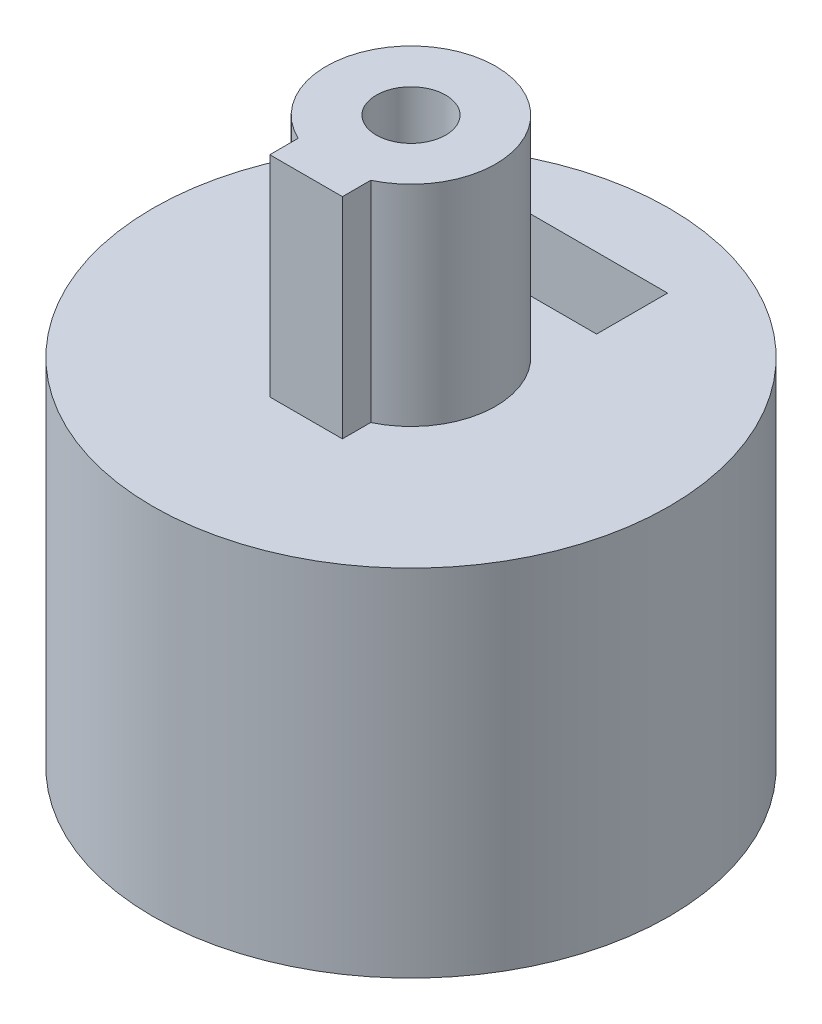
from build123d import *

# Parameters (mm, degrees)
SKETCH1_R           = 8
BOSS_EXTRUDE1_DEPTH = 10
SKETCH2_R           = 1.075
CUT_EXTRUDE1_DEPTH  = 9
SKETCH4_R           = 2.275
CUT_EXTRUDE4_DEPTH  = 11.0000001
SKETCH5_W           = 0.95
SKETCH5_H           = 7.069146706
BOSS_EXTRUDE2_DEPTH = 1.2
SKETCH7_R           = 8
BOSS_EXTRUDE3_DEPTH = 1
SKETCH8_R           = 2.625
SKETCH8_W           = 2.25
SKETCH8_H           = 1.25
BOSS_EXTRUDE4_DEPTH = 6.5
SKETCH9_R           = 1.075
CUT_EXTRUDE5_DEPTH  = 6
CUT_EXTRUDE2_START  = -3.5
CUT_EXTRUDE2_DEPTH  = 2.2


with BuildPart() as part:
    # Sketch1 → Boss-Extrude1 (new body)
    with BuildSketch(Plane(origin=(0, 0, 0), x_dir=(1, 0, 0), z_dir=(0, 1, 0))):
        Circle(SKETCH1_R)
    extrude(amount=BOSS_EXTRUDE1_DEPTH)

    # Sketch2 → Cut-Extrude1 (cut, through all)
    with BuildSketch(Plane.XY):
        with Locations((0, 7)):
            Circle(SKETCH2_R)
    extrude(amount=-CUT_EXTRUDE1_DEPTH, mode=Mode.SUBTRACT)

    # Sketch4 → Cut-Extrude4 (cut, through all)
    with BuildSketch(Plane(origin=(0, 0, 0), x_dir=(1, 0, 0), z_dir=(0, 1, 0))):
        Circle(SKETCH4_R)
    extrude(amount=CUT_EXTRUDE4_DEPTH, mode=Mode.SUBTRACT)

    # Sketch5 → Boss-Extrude2 (add)
    with BuildSketch(Plane(origin=(0, 10, 0), x_dir=(1, 0, 0), z_dir=(0, 1, 0))):
        Rectangle(SKETCH5_W, SKETCH5_H)
    extrude(amount=-BOSS_EXTRUDE2_DEPTH)

    # Sketch7 → Boss-Extrude3 (add)
    with BuildSketch(Plane(origin=(0, 10, 0), x_dir=(1, 0, 0), z_dir=(0, 1, 0))):
        Circle(SKETCH7_R)
    extrude(amount=BOSS_EXTRUDE3_DEPTH)

    # Sketch8 → Boss-Extrude4 (add)
    with BuildSketch(Plane(origin=(0, 11, 0), x_dir=(1, 0, 0), z_dir=(0, 1, 0))):
        Circle(SKETCH8_R)
        with Locations((0, -2.625)):
            Rectangle(SKETCH8_W, SKETCH8_H)
    extrude(amount=BOSS_EXTRUDE4_DEPTH)

    # Sketch9 → Cut-Extrude5 (cut)
    with BuildSketch(Plane(origin=(0, 17.5, 0), x_dir=(1, 0, 0), z_dir=(0, 1, 0))):
        Circle(SKETCH9_R)
    extrude(amount=-CUT_EXTRUDE5_DEPTH, mode=Mode.SUBTRACT)

    # Sketch3 → Cut-Extrude2 (cut)
    with BuildSketch(Plane.XY.offset(CUT_EXTRUDE2_START)):
        Polygon((0, 4.401923789), (2.25, 5.700961894), (2.25, 8.299038106), (2.25, 11.472802467), (-2.25, 11.472802467), (-2.25, 8.299038106), (-2.25, 5.700961894), align=None)
    extrude(amount=-CUT_EXTRUDE2_DEPTH, mode=Mode.SUBTRACT)


solid = part.part
